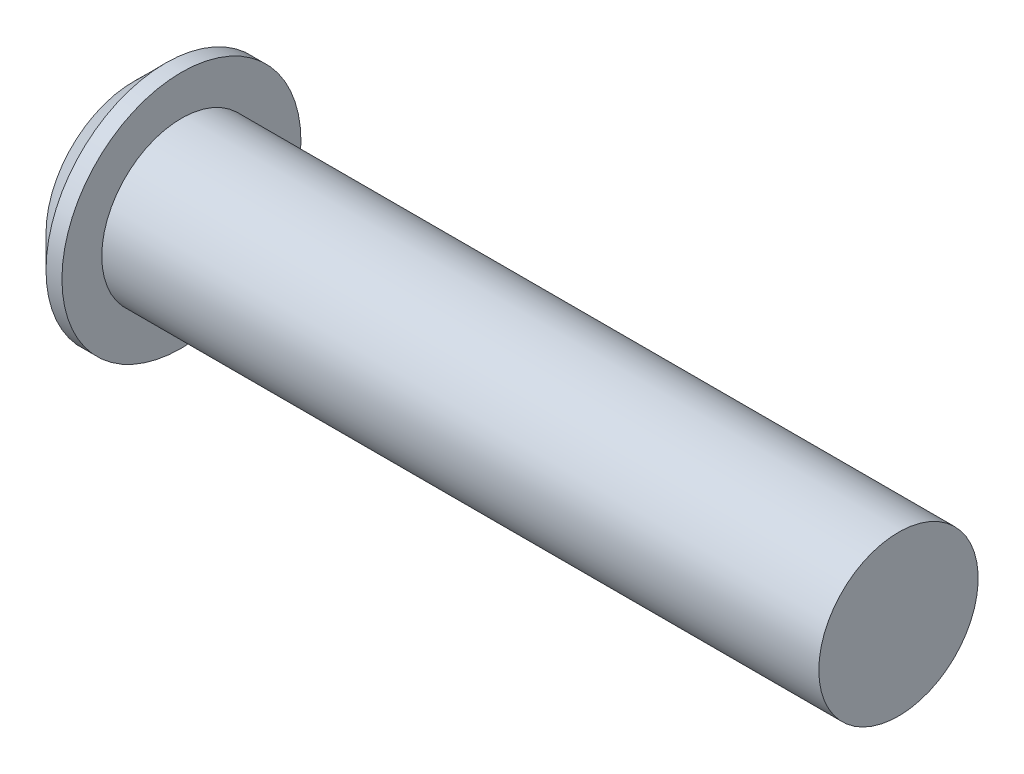
from build123d import *

# Parameters (mm, degrees)
IZIM1_W   = 3
IZIM1_H   = 7.5
IZIM1_W_2 = 45
IZIM1_H_2 = 5
PAH1_SIZE = 2


with BuildPart() as part:
    # Çizim1 → Döndür1 (revolve)
    with BuildSketch(Plane.XY):
        with Locations((1.5, 3.75)):
            Rectangle(IZIM1_W, IZIM1_H)
        with Locations((25.5, 2.5)):
            Rectangle(IZIM1_W_2, IZIM1_H_2)
    revolve(axis=Axis((3, 0, 0), (1, 0, 0)))

    # Pah1
    pah1_edges = [part.edges().sort_by_distance(p)[0] for p in [
        (0, -7.5, 0),
    ]]
    chamfer(pah1_edges, length=PAH1_SIZE)


solid = part.part
